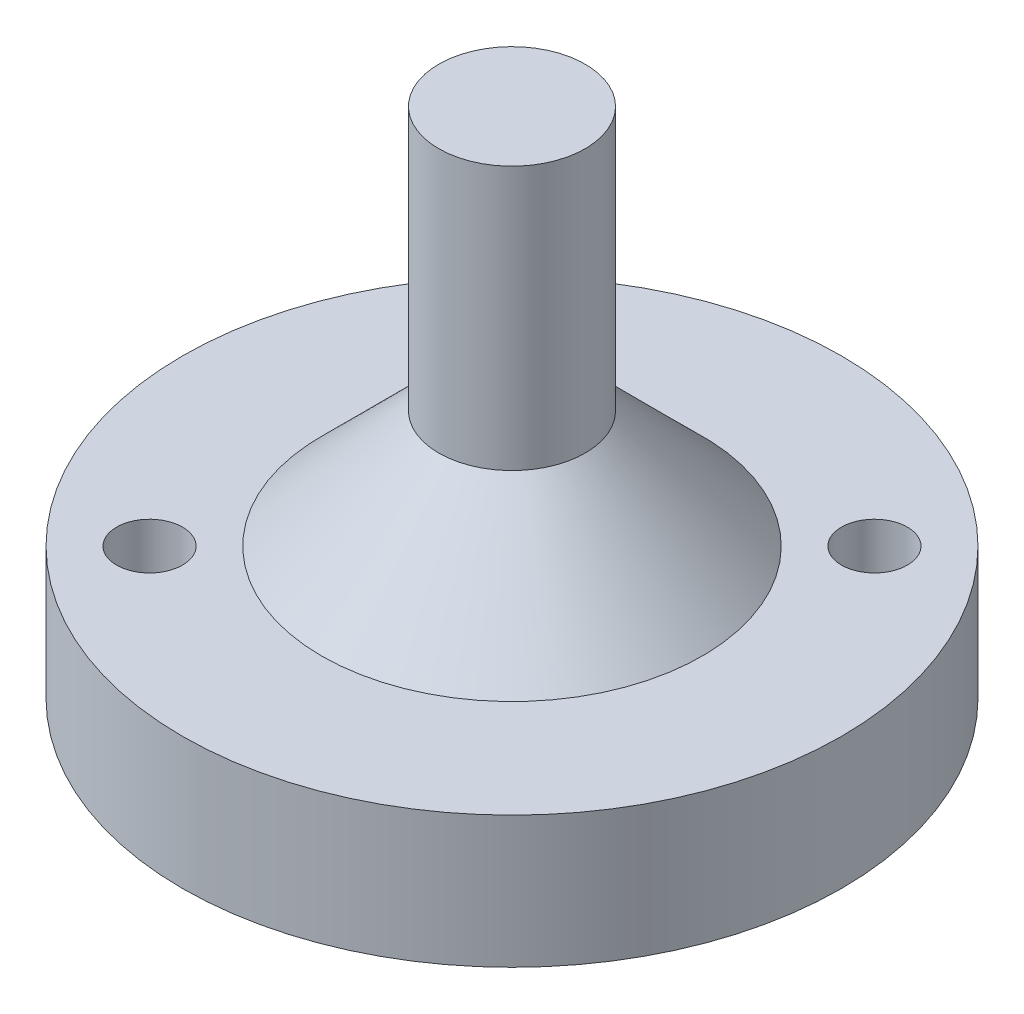
from build123d import *

# Parameters (mm, degrees)
SKETCH1_R           = 22.5
BOSS_EXTRUDE1_DEPTH = 9
SKETCH2_R           = 2.25
CUT_EXTRUDE1_DEPTH  = 10
CIRPATTERN1_COUNT   = 2
SKETCH3_R           = 5
BOSS_EXTRUDE2_DEPTH = 26
CHAMFER1_SIZE       = 8
SKETCH6_R           = 9.25
CUT_EXTRUDE4_DEPTH  = 7


with BuildPart() as part:
    # Sketch1 → Boss-Extrude1 (new body)
    with BuildSketch(Plane(origin=(0, 0, 0), x_dir=(1, 0, 0), z_dir=(0, 1, 0))):
        Circle(SKETCH1_R)
    extrude(amount=BOSS_EXTRUDE1_DEPTH)

    # Sketch2 → Cut-Extrude1 (cut, through all)
    with BuildSketch(Plane(origin=(0, 9, 0), x_dir=(1, 0, 0), z_dir=(0, 1, 0))):
        with Locations((12.374368671, 12.374368671)):
            Circle(SKETCH2_R)
    cut_extrude1 = extrude(amount=-CUT_EXTRUDE1_DEPTH, mode=Mode.SUBTRACT)

    # CirPattern1: Cut-Extrude1 ×2 about axis
    cirpattern1_axis = Axis((0, 0, 0), (0, 1, 0))
    for i in range(1, CIRPATTERN1_COUNT):
        add(cut_extrude1.rotate(cirpattern1_axis, i * 360 / CIRPATTERN1_COUNT), mode=Mode.SUBTRACT)

    # Sketch3 → Boss-Extrude2 (add)
    with BuildSketch(Plane(origin=(0, 9, 0), x_dir=(1, 0, 0), z_dir=(0, 1, 0))):
        Circle(SKETCH3_R)
    extrude(amount=BOSS_EXTRUDE2_DEPTH)

    # Chamfer1
    chamfer1_edges = [part.edges().sort_by_distance(p)[0] for p in [
        (-5, 9, 0),
    ]]
    chamfer(chamfer1_edges, length=CHAMFER1_SIZE)

    # Sketch6 → Cut-Extrude4 (cut)
    with BuildSketch(Plane.XZ):
        Circle(SKETCH6_R)
    extrude(amount=-CUT_EXTRUDE4_DEPTH, mode=Mode.SUBTRACT)


solid = part.part
